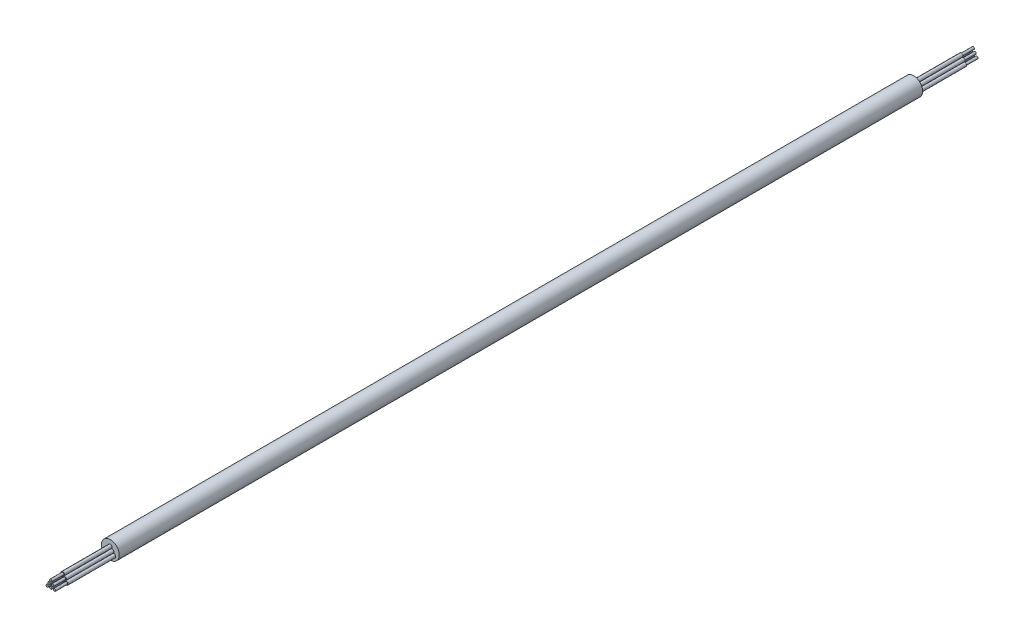
from build123d import *

# Parameters (mm, degrees)
SKETCH_1_R             = 0.2
EXTRUDE_9_DEPTH        = 145
EXTRUDE_9_DEPTH_BACK   = 10
EXTRUDE_9_2_DEPTH      = 145
EXTRUDE_9_2_DEPTH_BACK = 10
EXTRUDE_9_3_DEPTH      = 145
EXTRUDE_9_3_DEPTH_BACK = 10
EXTRUDE_9_4_DEPTH      = 145
EXTRUDE_9_4_DEPTH_BACK = 10
EXTRUDE_9_5_DEPTH      = 145
EXTRUDE_9_5_DEPTH_BACK = 10
EXTRUDE_9_6_DEPTH      = 145
EXTRUDE_9_6_DEPTH_BACK = 10
SKETCH_1_12_R          = 0.3
EXTRUDE_10_DEPTH       = 143
EXTRUDE_10_DEPTH_BACK  = 8
SKETCH_1_13_R          = 1.5
EXTRUDE_11_DEPTH       = 135


with BuildPart() as part:
    # Sketch 1 → Extrude 9 (new body, two sides)
    with BuildSketch(Plane.XY) as extrude_9_sk:
        with Locations((-0.31, 0)):
            Circle(SKETCH_1_R)
    extrude(amount=EXTRUDE_9_DEPTH)
    extrude(extrude_9_sk.sketch, amount=-EXTRUDE_9_DEPTH_BACK)



with BuildPart() as body_2:
    # Sketch 1 → Extrude 9 2 (new body, two sides)
    with BuildSketch(Plane.XY) as extrude_9_2_sk:
        with Locations((0, 0.53)):
            Circle(SKETCH_1_R)
    extrude(amount=EXTRUDE_9_2_DEPTH)
    extrude(extrude_9_2_sk.sketch, amount=-EXTRUDE_9_2_DEPTH_BACK)


with BuildPart() as body_3:
    # Sketch 1 → Extrude 9 3 (new body, two sides)
    with BuildSketch(Plane.XY) as extrude_9_3_sk:
        with Locations((0.31, 0)):
            Circle(SKETCH_1_R)
    extrude(amount=EXTRUDE_9_3_DEPTH)
    extrude(extrude_9_3_sk.sketch, amount=-EXTRUDE_9_3_DEPTH_BACK)


with BuildPart() as body_4:
    # Sketch 1 → Extrude 9 4 (new body, two sides)
    with BuildSketch(Plane.XY) as extrude_9_4_sk:
        with Locations((0, -0.53)):
            Circle(SKETCH_1_R)
    extrude(amount=EXTRUDE_9_4_DEPTH)
    extrude(extrude_9_4_sk.sketch, amount=-EXTRUDE_9_4_DEPTH_BACK)


with BuildPart() as body_5:
    # Sketch 1 → Extrude 9 5 (new body, two sides)
    with BuildSketch(Plane.XY) as extrude_9_5_sk:
        with Locations((-0.61, -0.53)):
            Circle(SKETCH_1_R)
    extrude(amount=EXTRUDE_9_5_DEPTH)
    extrude(extrude_9_5_sk.sketch, amount=-EXTRUDE_9_5_DEPTH_BACK)


with BuildPart() as body_6:
    # Sketch 1 → Extrude 9 6 (new body, two sides)
    with BuildSketch(Plane.XY) as extrude_9_6_sk:
        with Locations((0.61, -0.53)):
            Circle(SKETCH_1_R)
    extrude(amount=EXTRUDE_9_6_DEPTH)
    extrude(extrude_9_6_sk.sketch, amount=-EXTRUDE_9_6_DEPTH_BACK)


with BuildPart() as part_1:
    add(part.part)

    add(body_2.part)  # Extrude 10 merges body 2

    add(body_3.part)  # Extrude 10 merges body 3

    add(body_4.part)  # Extrude 10 merges body 4

    add(body_5.part)  # Extrude 10 merges body 5

    add(body_6.part)  # Extrude 10 merges body 6
    # Sketch 1_12 → Extrude 10 (add, two sides)
    with BuildSketch(Plane.XY) as extrude_10_sk:
        with Locations((0.31, 0)):
            Circle(SKETCH_1_12_R)
        with Locations((-0.31, 0)):
            Circle(SKETCH_1_12_R)
        with Locations((0, 0.53)):
            Circle(SKETCH_1_12_R)
        with Locations((0, -0.53)):
            Circle(SKETCH_1_12_R)
        with Locations((-0.61, -0.53)):
            Circle(SKETCH_1_12_R)
        with Locations((0.61, -0.53)):
            Circle(SKETCH_1_12_R)
    extrude(amount=EXTRUDE_10_DEPTH)
    extrude(extrude_10_sk.sketch, amount=-EXTRUDE_10_DEPTH_BACK)

    # Sketch 1_13 → Extrude 11 (add)
    with BuildSketch(Plane.XY):
        Circle(SKETCH_1_13_R)
    extrude(amount=EXTRUDE_11_DEPTH)


solid = part_1.part
